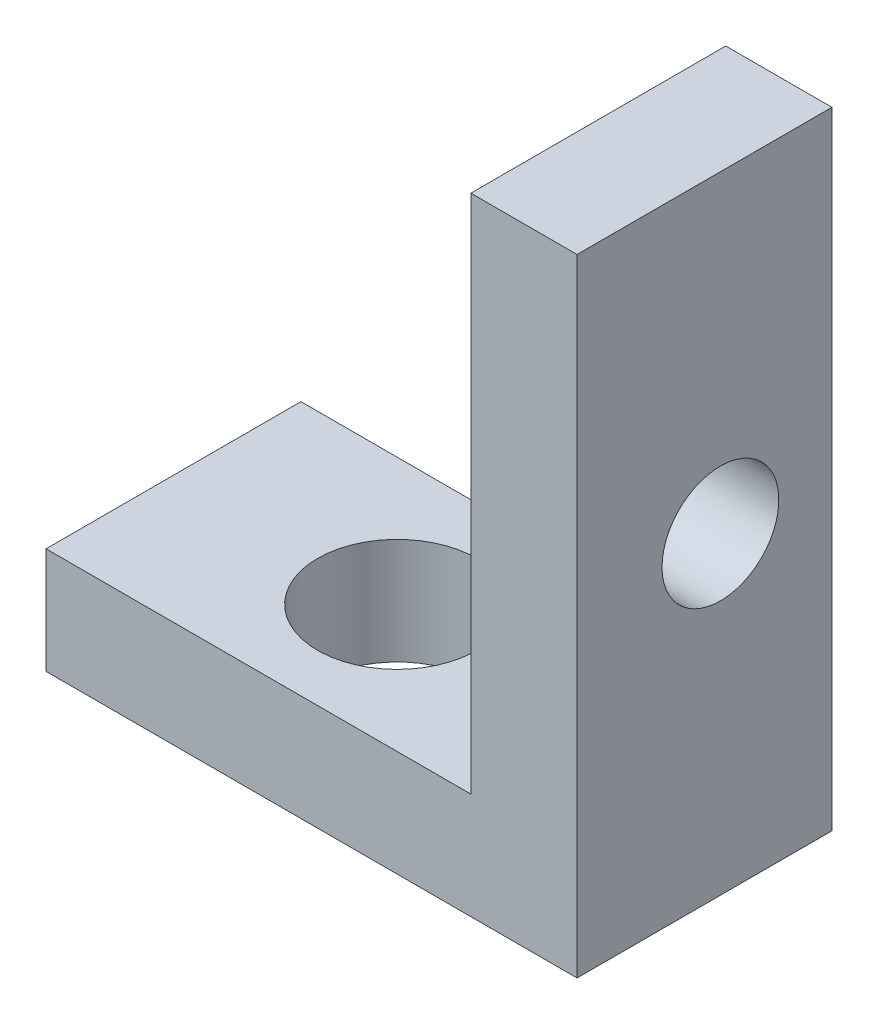
from build123d import *

# Parameters (mm, degrees)
BOSS_EXTRUDE1_DEPTH = 4.8
CUT_EXTRUDE1_REACH  = 4
SKETCH2_R           = 1.1
CUT_EXTRUDE2_REACH  = 4
SKETCH3_R           = 1.5


with BuildPart() as part:
    # Sketch1 → Boss-Extrude1 (new body)
    with BuildSketch(Plane.XY):
        Polygon((0, 0), (0, 11.8), (-2, 11.8), (-2, 2), (-10, 2), (-10, 0), align=None)
    extrude(amount=BOSS_EXTRUDE1_DEPTH)

    # Sketch2 → Cut-Extrude1 (cut, up to next)
    with BuildSketch(Plane.ZY.offset(2), mode=Mode.PRIVATE) as cut_extrude1_sk1:
        with Locations((2.1, 5.9)):
            Circle(SKETCH2_R)
    cut_extrude1_tool1 = extrude(cut_extrude1_sk1.sketch, amount=-CUT_EXTRUDE1_REACH, mode=Mode.PRIVATE) & part.part
    add(cut_extrude1_tool1.solids().sort_by_distance((-2, 5.9, 2.1))[0], mode=Mode.SUBTRACT)

    # Sketch3 → Cut-Extrude2 (cut, up to next)
    with BuildSketch(Plane(origin=(0, 2, 0), x_dir=(1, 0, 0), z_dir=(0, 1, 0)), mode=Mode.PRIVATE) as cut_extrude2_sk1:
        with Locations((-5.786663097, -2.4)):
            Circle(SKETCH3_R)
    cut_extrude2_tool1 = extrude(cut_extrude2_sk1.sketch, amount=-CUT_EXTRUDE2_REACH, mode=Mode.PRIVATE) & part.part
    add(cut_extrude2_tool1.solids().sort_by_distance((-5.786663, 2, 2.4))[0], mode=Mode.SUBTRACT)


solid = part.part
